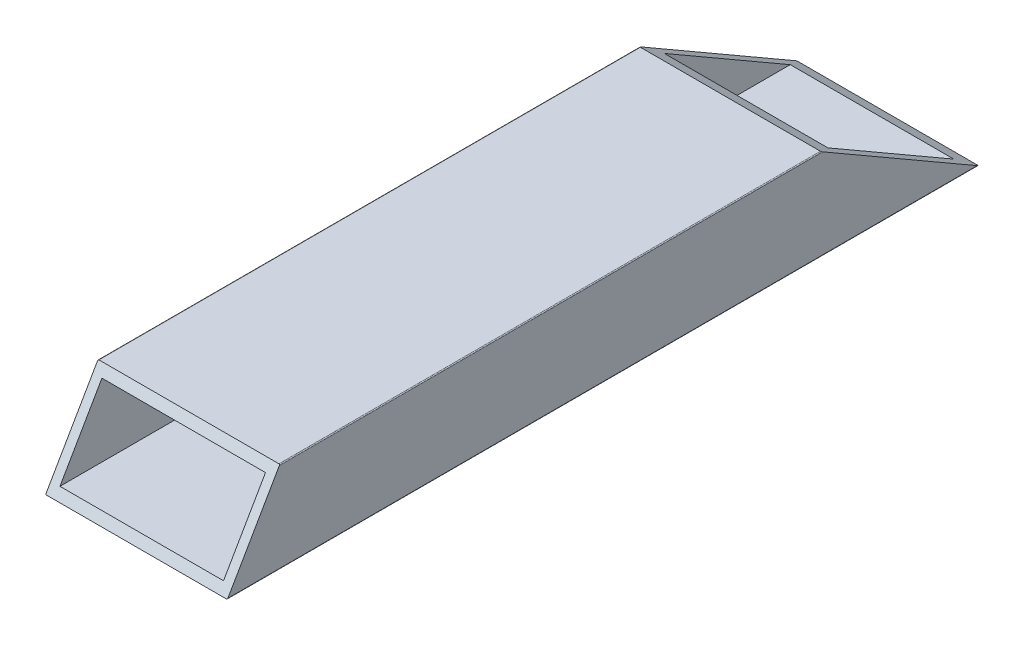
from build123d import *

# Parameters (mm, degrees)
SKETCH1_W           = 36
SKETCH1_H           = 16
BOSS_EXTRUDE1_DEPTH = 165.35
SKEW_CUT_DEPTH      = 172.291046176


with BuildPart() as part:
    # Sketch1 → Boss-Extrude1 (new body)
    with BuildSketch(Plane.XY):
        with BuildLine():
            Line((0.2, 0), (39.8, 0))
            ThreePointArc((39.8, 0), (39.941421356, 0.058578644), (40, 0.2))
            Line((40, 0.2), (40, 19.8))
            ThreePointArc((40, 19.8), (39.941421356, 19.941421356), (39.8, 20))
            Line((39.8, 20), (0.2, 20))
            ThreePointArc((0.2, 20), (0.058578644, 19.941421356), (0, 19.8))
            Line((0, 19.8), (0, 0.2))
            ThreePointArc((0, 0.2), (0.058578644, 0.058578644), (0.2, 0))
        make_face()
        with Locations((20, 10)):
            Rectangle(SKETCH1_W, SKETCH1_H, mode=Mode.SUBTRACT)
    extrude(amount=BOSS_EXTRUDE1_DEPTH)

    # Sketch2 → Skew Cut (cut, through all)
    with BuildSketch(Plane.ZY):
        Polygon((0, 20), (34.641016151, 20), (0, 0), align=None)
        Polygon((165.35, 0), (153.802994616, 20), (165.35, 20), align=None)
    extrude(amount=-SKEW_CUT_DEPTH, mode=Mode.SUBTRACT)


solid = part.part
